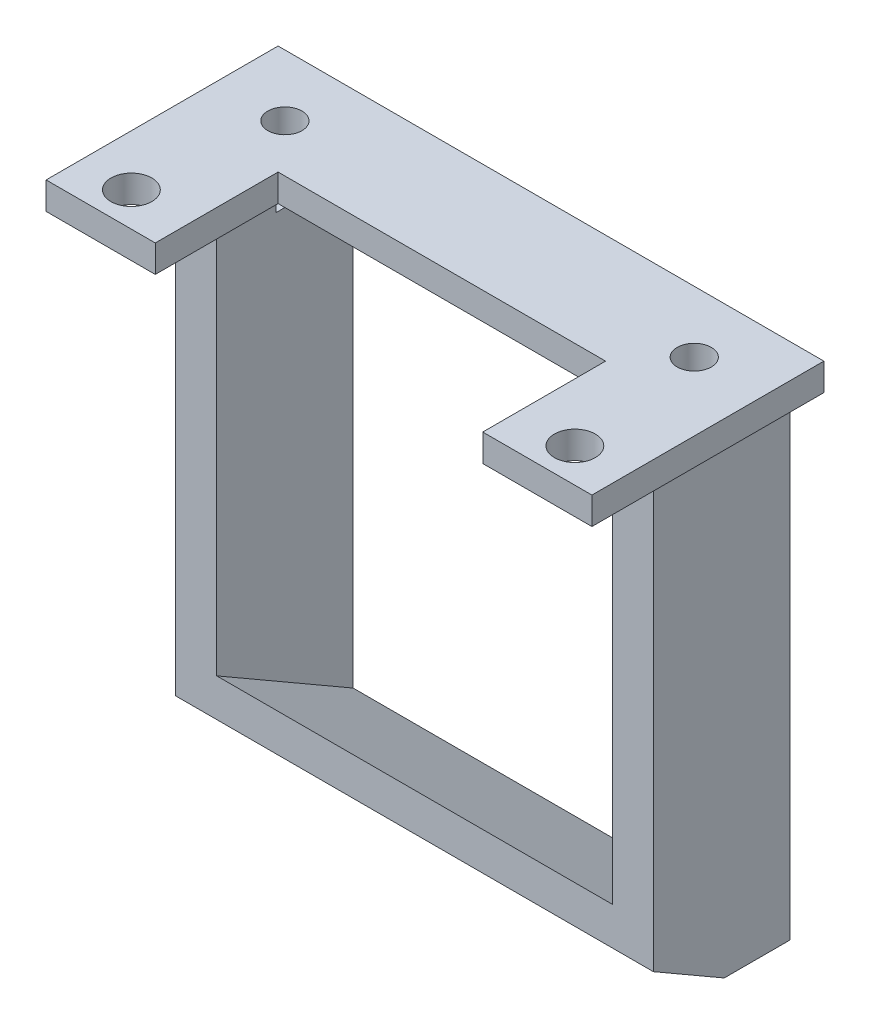
from build123d import *

# Parameters (mm, degrees)
SKETCH1_W           = 8
SKETCH1_H           = 17
SKETCH1_W_2         = 24
SKETCH1_H_2         = 8
BOSS_EXTRUDE1_DEPTH = 2
SKETCH4_W           = 3
SKETCH4_H           = 10
BOSS_EXTRUDE4_DEPTH = 36
BOSS_EXTRUDE5_REACH = 36.5
CUT_EXTRUDE3_DEPTH  = 38.5
SKETCH7_R           = 1.25
SKETCH7_R_2         = 1.5
CUT_EXTRUDE4_DEPTH  = 5


with BuildPart() as part:
    # Sketch1 → Boss-Extrude1 (new body)
    with BuildSketch(Plane(origin=(0, 0, 0), x_dir=(1, 0, 0), z_dir=(0, 1, 0))):
        with Locations((-17.713965849, 5.014073333)):
            Rectangle(SKETCH1_W, SKETCH1_H)
        with Locations((-1.713965849, 9.514073333)):
            Rectangle(SKETCH1_W_2, SKETCH1_H_2)
        with Locations((14.286034151, 5.014073333)):
            Rectangle(SKETCH1_W, SKETCH1_H)
    extrude(amount=-BOSS_EXTRUDE1_DEPTH)

    # Sketch4 → Boss-Extrude4 (add)
    with BuildSketch(Plane(origin=(0, -2, 0), x_dir=(-1, 0, 0), z_dir=(0, -1, 0))):
        with Locations((-14.286034151, 8.514073333)):
            Rectangle(SKETCH4_W, SKETCH4_H)
        with Locations((17.713965849, 8.514073333)):
            Rectangle(SKETCH4_W, SKETCH4_H)
    extrude(amount=BOSS_EXTRUDE4_DEPTH)

    # Sketch5 → Boss-Extrude5 (add, up to next)
    with BuildSketch(Plane.ZY.offset(-12.786034151), mode=Mode.PRIVATE) as boss_extrude5_sk1:
        Polygon((-13.514073333, -38), (-3.514073333, -32.226497308), (-3.514073333, -38), align=None)
    boss_extrude5_tool1 = extrude(boss_extrude5_sk1.sketch, amount=BOSS_EXTRUDE5_REACH, mode=Mode.PRIVATE) - part.part
    add(boss_extrude5_tool1.solids().sort_by_distance((12.786034, -36.075499, -6.847407))[0])

    # Sketch6 → Cut-Extrude3 (cut, through all)
    with BuildSketch(Plane.ZY.offset(19.213965849)):
        Polygon((-3.514073333, -38), (-3.514073333, -35), (-8.710225756, -38), align=None)
    extrude(amount=-CUT_EXTRUDE3_DEPTH, mode=Mode.SUBTRACT)

    # Sketch7 → Cut-Extrude4 (cut)
    with BuildSketch(Plane(origin=(0, 0, 0), x_dir=(1, 0, 0), z_dir=(0, 1, 0))):
        with Locations((-16.713965849, 9.014073333)):
            Circle(SKETCH7_R)
        with Locations((13.286034151, 9.014073333)):
            Circle(SKETCH7_R)
        with Locations((-17.963965849, -0.985926667)):
            Circle(SKETCH7_R_2)
        with Locations((14.536034151, -0.985926667)):
            Circle(SKETCH7_R_2)
    extrude(amount=-CUT_EXTRUDE4_DEPTH, mode=Mode.SUBTRACT)


solid = part.part
